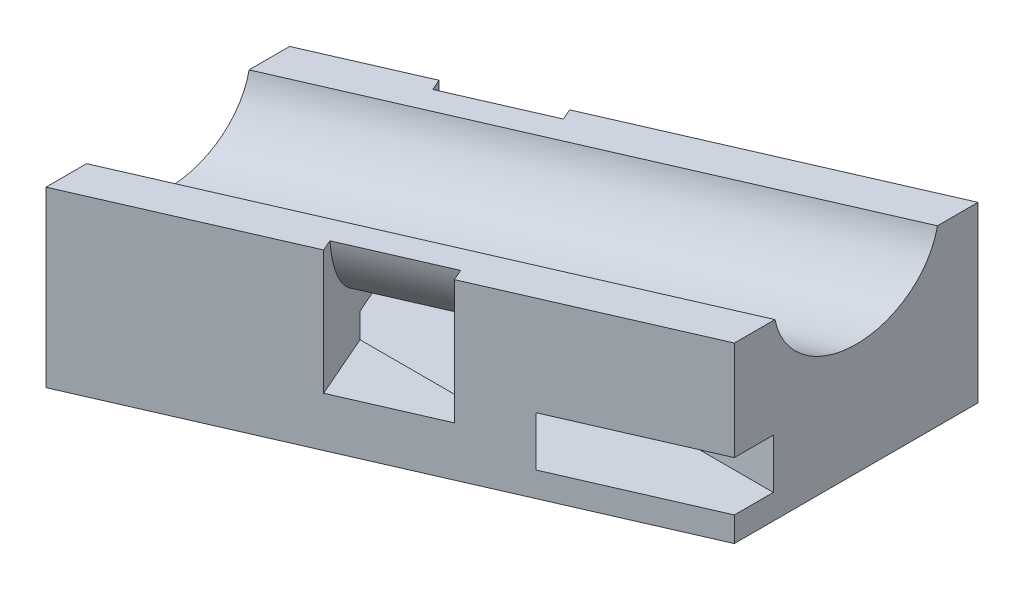
from build123d import *

# Parameters (mm, degrees)
BOSS_EXTRUDE2_DEPTH     = 7
CUT_EXTRUDE4_DEPTH      = 25
CUT_EXTRUDE7_DEPTH      = 4
SKETCH6_W               = 4
SKETCH6_H               = 2
CUT_EXTRUDE5_DEPTH      = 23.912878475
CUT_EXTRUDE5_DEPTH_BACK = 4.6
SKETCH12_W              = 3.6
SKETCH12_H              = 9.819805061
CUT_EXTRUDE10_DEPTH     = 8
SKETCH13_W              = 3.6
SKETCH13_H              = 9.819805061
CUT_EXTRUDE11_DEPTH     = 8


with BuildPart() as part:
    # Sketch2 → Boss-Extrude2 (new body)
    with BuildSketch(Plane(origin=(0, 0, 0), x_dir=(1, 0, 0), z_dir=(0, 1, 0))):
        Polygon((0, 0), (-3.6, 8.248636251), (19.312878475, 18.248636251), (22.912878475, 10), align=None)
    extrude(amount=BOSS_EXTRUDE2_DEPTH)

    # Sketch4 → Cut-Extrude4 (cut)
    with BuildSketch(Plane(origin=(0, 0, 0), x_dir=(0.4, 0, 0.916515139), z_dir=(-0.916515139, 0, 0.4))):
        with BuildLine():
            Line((-7.5, 7), (-1.5, 7))
            ThreePointArc((-1.5, 7), (-4.5, 4.5), (-7.5, 7))
        make_face()
    extrude(amount=-CUT_EXTRUDE4_DEPTH, mode=Mode.SUBTRACT)

    # Sketch8 → Cut-Extrude7 (cut)
    with BuildSketch(Plane(origin=(11.456439237, 0, -5), x_dir=(-0.4, 0, -0.916515139), z_dir=(0.916515139, 0, -0.4))):
        with BuildLine():
            Line((0.48751947, 7), (0, 7))
            Line((0, 7), (0, 2))
            Line((0, 2), (9, 2))
            Line((9, 2), (9, 7))
            Line((9, 7), (8.51248053, 7))
            ThreePointArc((8.51248053, 7), (4.5, 3.5), (0.48751947, 7))
        make_face()
    extrude(amount=-CUT_EXTRUDE7_DEPTH, mode=Mode.SUBTRACT)

    # Sketch6 → Cut-Extrude5 (cut, two sides)
    with BuildSketch(Plane(origin=(0, 0, 0), x_dir=(0, 0, -1), z_dir=(1, 0, 0))) as cut_extrude5_sk:
        with Locations((8, 2)):
            Rectangle(SKETCH6_W, SKETCH6_H)
    extrude(amount=CUT_EXTRUDE5_DEPTH, mode=Mode.SUBTRACT)
    extrude(cut_extrude5_sk.sketch, amount=-CUT_EXTRUDE5_DEPTH_BACK, mode=Mode.SUBTRACT)

    # Sketch12 → Cut-Extrude10 (cut, through all)
    with BuildSketch(Plane(origin=(0, 0, 0), x_dir=(1, 0, 0), z_dir=(0, 1, 0))):
        with Locations((21.112878475, 13.338733721)):
            Rectangle(SKETCH12_W, SKETCH12_H)
    extrude(amount=CUT_EXTRUDE10_DEPTH, mode=Mode.SUBTRACT)

    # Sketch13 → Cut-Extrude11 (cut, through all)
    with BuildSketch(Plane(origin=(0, 0, 0), x_dir=(1, 0, 0), z_dir=(0, 1, 0))):
        with Locations((-1.8, 4.909902531)):
            Rectangle(SKETCH13_W, SKETCH13_H)
    extrude(amount=CUT_EXTRUDE11_DEPTH, mode=Mode.SUBTRACT)


solid = part.part
